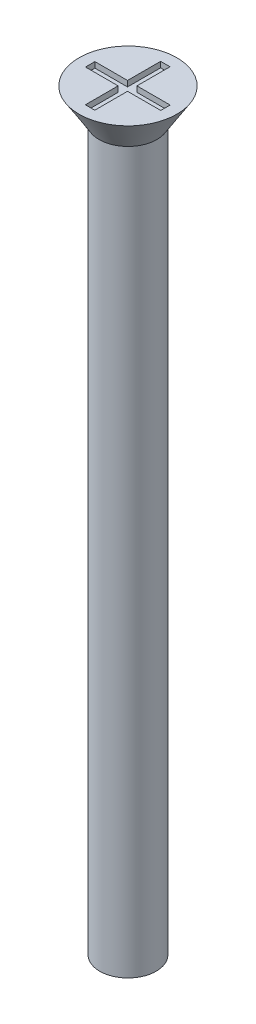
from build123d import *

# Parameters (mm, degrees)
SKETCH1_R           = 1.5
BOSS_EXTRUDE1_DEPTH = 40
SKETCH2_R           = 2.6
BOSS_EXTRUDE2_DEPTH = 1.7
BOSS_EXTRUDE2_TAPER = 32
SKETCH3_W           = 0.5
SKETCH3_H           = 1.758378485
SKETCH3_H_2         = 1.741621515
SKETCH3_W_2         = 1.734727157
SKETCH3_H_3         = 0.5
SKETCH3_W_3         = 1.765272843
CUT_EXTRUDE1_DEPTH  = 0.3


with BuildPart() as part:
    # Sketch1 → Boss-Extrude1 (new body)
    with BuildSketch(Plane(origin=(0, 0, 0), x_dir=(1, 0, 0), z_dir=(0, 1, 0))):
        Circle(SKETCH1_R)
    extrude(amount=BOSS_EXTRUDE1_DEPTH)

    # Sketch2 → Boss-Extrude2 (add)
    with BuildSketch(Plane(origin=(0, 40, 0), x_dir=(1, 0, 0), z_dir=(0, 1, 0))):
        Circle(SKETCH2_R)
    extrude(amount=-BOSS_EXTRUDE2_DEPTH, taper=BOSS_EXTRUDE2_TAPER)

    # Sketch3 → Cut-Extrude1 (cut)
    with BuildSketch(Plane(origin=(0, 40, 0), x_dir=(1, 0, 0), z_dir=(0, 1, 0))):
        with Locations((-0.015272843, 1.120810757)):
            Rectangle(SKETCH3_W, SKETCH3_H)
        with Locations((-0.015272843, -1.129189243)):
            Rectangle(SKETCH3_W, SKETCH3_H_2)
        with Locations((-1.132636421, -0.008378485)):
            Rectangle(SKETCH3_W_2, SKETCH3_H_3)
        with Locations((1.117363579, -0.008378485)):
            Rectangle(SKETCH3_W_3, SKETCH3_H_3)
        with Locations((-0.015272843, -0.008378485)):
            Rectangle(SKETCH3_W, SKETCH3_H_3)
    extrude(amount=-CUT_EXTRUDE1_DEPTH, mode=Mode.SUBTRACT)


solid = part.part
